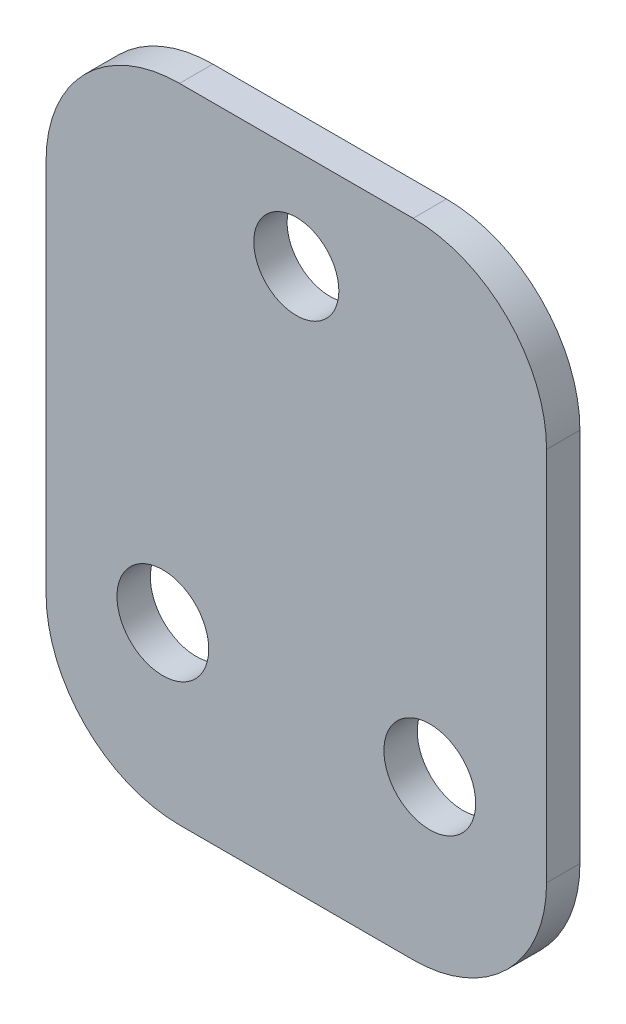
from build123d import *

# Parameters (mm, degrees)
SKETCH1_W           = 30
SKETCH1_H           = 38.5
SKETCH1_R           = 2.55
SKETCH1_R_2         = 2.75
BOSS_EXTRUDE1_DEPTH = 2
FILLET1_R           = 8


with BuildPart() as part:
    # Sketch1 → Boss-Extrude1 (new body)
    with BuildSketch(Plane.XY):
        with Locations((0, -0.75)):
            Rectangle(SKETCH1_W, SKETCH1_H)
        with Locations((0, 12.5)):
            Circle(SKETCH1_R, mode=Mode.SUBTRACT)
        with Locations((-8, -10)):
            Circle(SKETCH1_R_2, mode=Mode.SUBTRACT)
        with Locations((8, -10)):
            Circle(SKETCH1_R_2, mode=Mode.SUBTRACT)
    extrude(amount=BOSS_EXTRUDE1_DEPTH)

    # Fillet1
    fillet1_edges = [part.edges().sort_by_distance(p)[0] for p in [
        (15, -20, 1),
        (-15, -20, 1),
        (-15, 18.5, 1),
        (15, 18.5, 1),
    ]]
    fillet(fillet1_edges, radius=FILLET1_R)


solid = part.part
